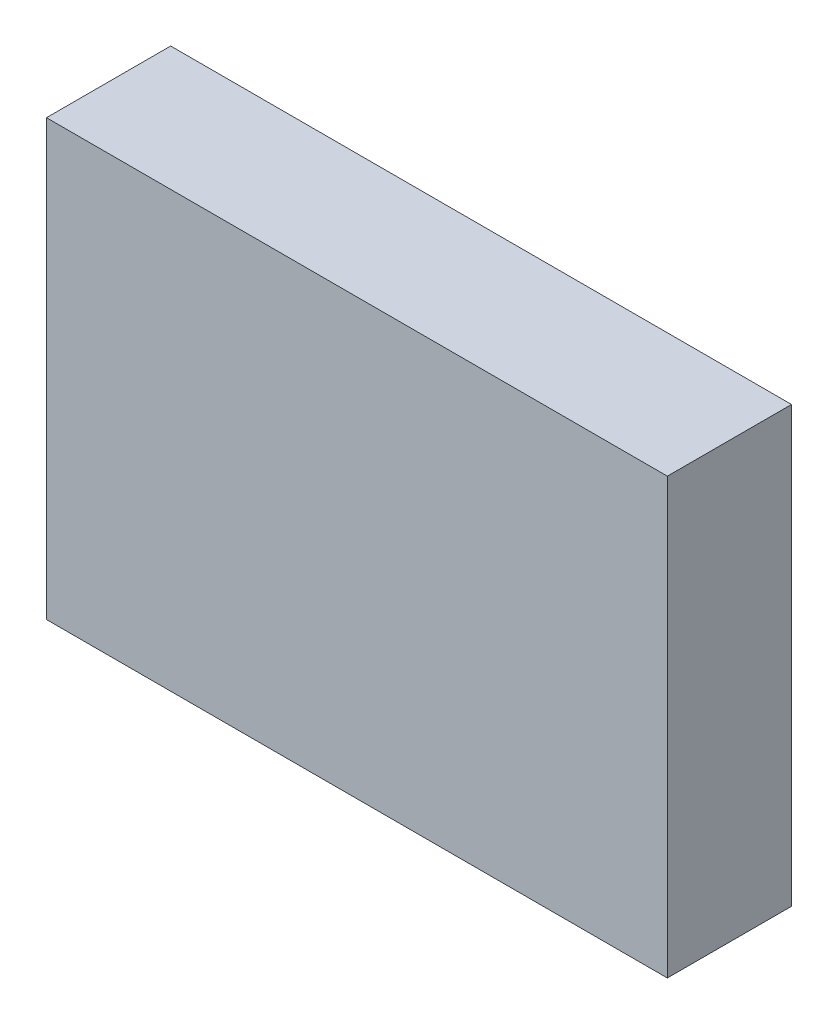
from build123d import *

# Parameters (mm, degrees)
SKETCH1_W           = 10
SKETCH1_H           = 2
BOSS_EXTRUDE1_DEPTH = 7


with BuildPart() as part:
    # Sketch1 → Boss-Extrude1 (new body)
    with BuildSketch(Plane(origin=(0, 0, 0), x_dir=(1, 0, 0), z_dir=(0, 1, 0))):
        with Locations((5, 1)):
            Rectangle(SKETCH1_W, SKETCH1_H)
    extrude(amount=BOSS_EXTRUDE1_DEPTH)


solid = part.part
